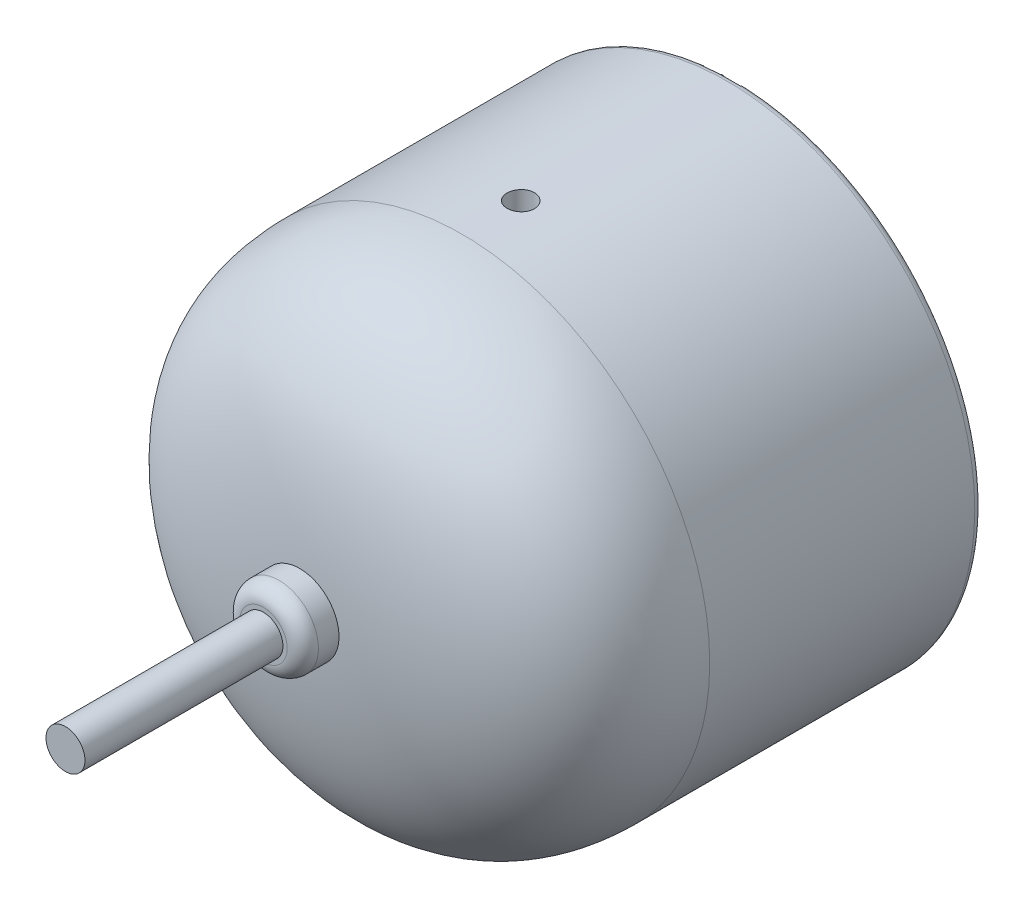
from build123d import *

# Parameters (mm, degrees)
CUT_EXTRUDE1_START  = -27
SKETCH6_R           = 1.75
CUT_EXTRUDE1_DEPTH  = 5.7500001
SKETCH7_R           = 5.05
BOSS_EXTRUDE2_DEPTH = 8
FILLET1_R           = 2
SKETCH8_R           = 2.5
BOSS_EXTRUDE3_DEPTH = 25.4


with BuildPart() as part:
    # Sketch3 → Revolve1 (revolve)
    with BuildSketch(Plane(origin=(0, 0, 0), x_dir=(1, 0, 0), z_dir=(0, 1, 0))):
        with BuildLine():
            Line((0, 25.32), (27.625, 25.32))
            Line((27.625, 25.32), (27.625, 26.5))
            ThreePointArc((27.625, 26.5), (27.917893219, 27.207106781), (28.625, 27.5))
            Line((28.625, 27.5), (30.75, 27.5))
            ThreePointArc((30.75, 27.5), (31.457106781, 27.207106781), (31.75, 26.5))
            Line((31.75, 26.5), (31.75, -7.5))
            add(Edge.make_bspline(
                [(0, -28.5), (23.295574904, -28.5), (31.75, -20.206509843), (31.75, -7.5)],
                knots=[0, 0, 0, 0, 1, 1, 1, 1], degree=3))
            Line((0, -28.5), (0, 25.32))
        make_face()
    revolve(axis=Axis((0, 0, -65.333333333), (0, 0, 1)))

    # Sketch6 → Cut-Extrude1 (cut, through all)
    with BuildSketch(Plane(origin=(0, 0, 0), x_dir=(1, 0, 0), z_dir=(0, 1, 0)).offset(CUT_EXTRUDE1_START)):
        Circle(SKETCH6_R)
    cut_extrude1 = extrude(amount=-CUT_EXTRUDE1_DEPTH, mode=Mode.SUBTRACT)

    # Mirror1: Cut-Extrude1 across plane
    add(cut_extrude1.mirror(Plane.ZX), mode=Mode.SUBTRACT)

    # Sketch7 → Boss-Extrude2 (add)
    with BuildSketch(Plane.XY.offset(25)):
        Circle(SKETCH7_R)
    extrude(amount=BOSS_EXTRUDE2_DEPTH)

    # Fillet1
    fillet1_edges = [part.edges().sort_by_distance(p)[0] for p in [
        (-5.05, 0, 33),
    ]]
    fillet(fillet1_edges, radius=FILLET1_R)

    # Sketch8 → Boss-Extrude3 (add)
    with BuildSketch(Plane.XY.offset(33)):
        Circle(SKETCH8_R)
    extrude(amount=BOSS_EXTRUDE3_DEPTH)


solid = part.part
